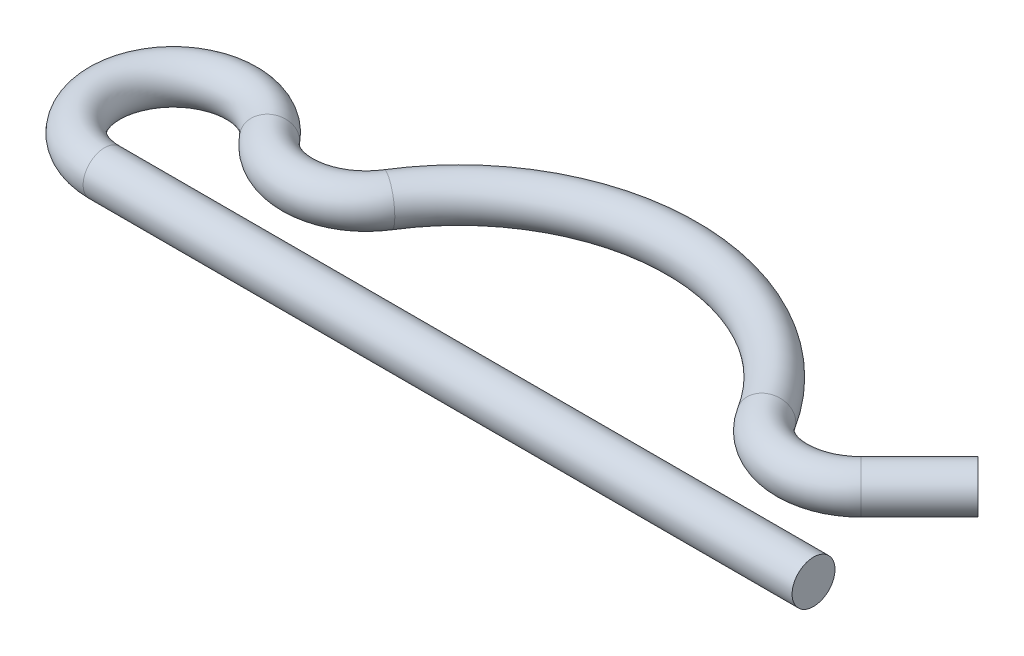
from build123d import *

# Parameters (mm, degrees)
SKETCH_2_R = 1.25


with BuildPart() as part:
    # По траектории1: sweep along a path in Эскиз1
    with BuildLine(Plane(origin=(0, 0, 0), x_dir=(1, 0, 0), z_dir=(0, 1, 0))) as sweep_1_path:
        Line((20.6672031, 0), (-20.6672031, 0))
        ThreePointArc((-20.6672031, 0), (-24.272754376, 5.732050808), (-17.544704101, 6.5))
        ThreePointArc((-17.544704101, 6.5), (-14.18789033, 5.006868824), (-11.028745078, 6.882352941))
        ThreePointArc((-11.028745078, 6.882352941), (0, 13), (11.028745078, 6.882352941))
        ThreePointArc((11.028745078, 6.882352941), (13.968203318, 5.025848219), (17.250632227, 6.171572875))
        Line((17.250632227, 6.171572875), (20.6672031, 9.588143749))
    # Эскиз2 → По траектории1 (sweep)
    with BuildSketch(Plane.ZY.offset(-20.6672031)):
        Circle(SKETCH_2_R)
    sweep(path=sweep_1_path.line)


solid = part.part
